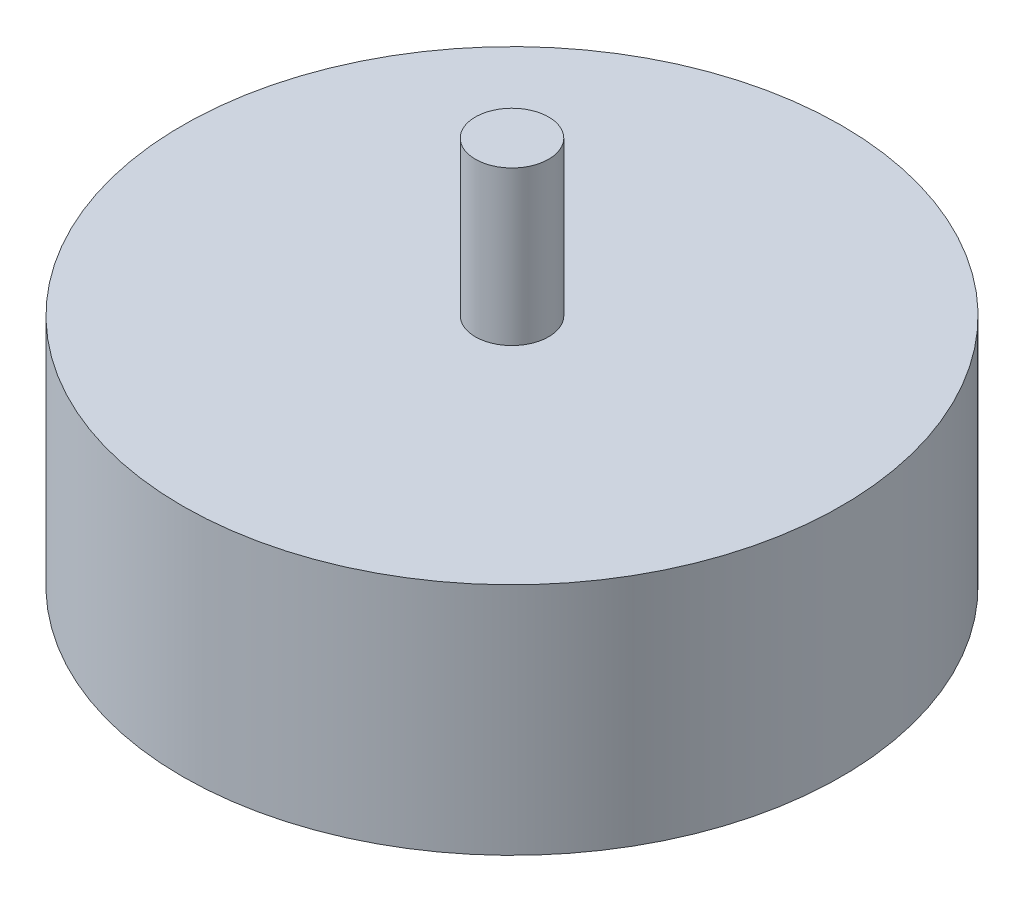
from build123d import *

# Parameters (mm, degrees)
SKETCH1_R           = 18
BOSS_EXTRUDE1_DEPTH = 12.8
SKETCH1_3_R         = 2
BOSS_EXTRUDE2_DEPTH = 21.2


with BuildPart() as part:
    # Sketch1 → Boss-Extrude1 (new body)
    with BuildSketch(Plane(origin=(0, 0, 0), x_dir=(1, 0, 0), z_dir=(0, 1, 0))):
        Circle(SKETCH1_R)
    extrude(amount=BOSS_EXTRUDE1_DEPTH)

    # Sketch1_3 → Boss-Extrude2 (add)
    with BuildSketch(Plane(origin=(0, 0, 0), x_dir=(1, 0, 0), z_dir=(0, 1, 0))):
        Circle(SKETCH1_3_R)
    extrude(amount=BOSS_EXTRUDE2_DEPTH)


solid = part.part
